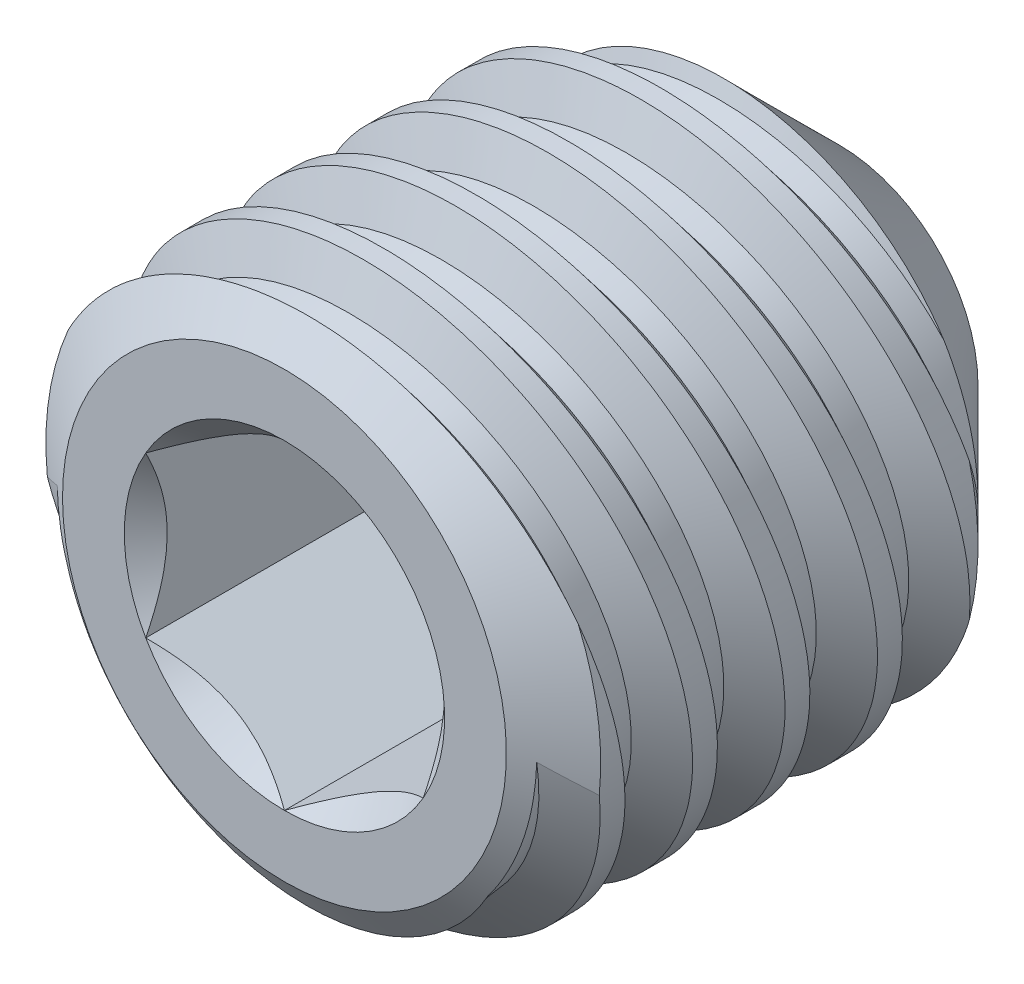
from build123d import *

# Parameters (mm, degrees)
LPATTERN1_COUNT     = 5
LPATTERN1_PITCH     = 0.5
LPATTERN1_COL_COUNT = 2
LPATTERN1_COL_PITCH = 0.5
CUT_EXTRUDE10_DEPTH = 1.5


with BuildPart() as part:
    # Sketch22 → Revolve1 (revolve)
    with BuildSketch(Plane(origin=(0, 0, 0), x_dir=(0, 0, -1), z_dir=(1, 0, 0)), mode=Mode.PRIVATE) as revolve1_sk:
        Polygon((-1.274677268, 0), (-1.274677268, 1.2), (-1.064615006, 1.5), (0.975322732, 1.5), (1.725322732, 0.75), (1.274677268, 0), align=None)
    revolve(revolve1_sk.sketch.rotate(Axis((0, 0, -1.274677268), (0, 0, -1)), 180), axis=Axis((0, 0, -1.274677268), (0, 0, -1)))

    # Sketch6 → Cut-Revolve8 (revolve, cut)
    with BuildSketch(Plane(origin=(0, 0, 0), x_dir=(0, 0, -1), z_dir=(1, 0, 0))):
        Polygon((0.573757931, 1.289561466), (0.45045869, 1.269011592), (0.251842859, 1.510274937), (0.6833902, 1.582199494), align=None)
    cut_revolve8 = revolve(axis=Axis((0, 0.089188249, -1.260452226), (0, -0.16439898730536787, 0.986393923832142)), mode=Mode.SUBTRACT)

    # LPattern1: Cut-Revolve8 ×5
    with Locations(*[(0, 0, i * LPATTERN1_PITCH) for i in range(1, LPATTERN1_COUNT)]):
        add(cut_revolve8, mode=Mode.SUBTRACT)

    # LPattern1 col: Cut-Revolve8 ×2
    with Locations(*[(0, 0, -i * LPATTERN1_COL_PITCH) for i in range(1, LPATTERN1_COL_COUNT)]):
        add(cut_revolve8, mode=Mode.SUBTRACT)

    # Sketch23 → Cut-Extrude10 (cut)
    with BuildSketch(Plane.XY.offset(1.274677268)):
        Polygon((0, 0.866025404), (-0.75, 0.433012702), (-0.75, -0.433012702), (0, -0.866025404), (0.75, -0.433012702), (0.75, 0.433012702), align=None)
    extrude(amount=-CUT_EXTRUDE10_DEPTH, mode=Mode.SUBTRACT)

    # Cut-Extrude11 cone 1 section (through the dimple's axis) → Cut-Extrude11 (revolve, cut)
    with BuildSketch(Plane(origin=(0, 0, 1.274677268), x_dir=(0, -1, 0), z_dir=(1, 0, 0))):
        Polygon((0, 0), (0.866025404, 0), (0, 0.866025404), align=None)
    revolve(axis=Axis((0, 0, 1.274677268), (0, 0, -1)), mode=Mode.SUBTRACT)

    # Cut-Extrude12 cone 1 section (through the dimple's axis) → Cut-Extrude12 (revolve, cut)
    with BuildSketch(Plane(origin=(0, 0, -0.225322732), x_dir=(0, -1, 0), z_dir=(1, 0, 0))):
        Polygon((0, 0), (0.75, 0), (0, 0.450645464), align=None)
    revolve(axis=Axis((0, 0, -0.225322732), (0, 0, -1)), mode=Mode.SUBTRACT)


solid = part.part
